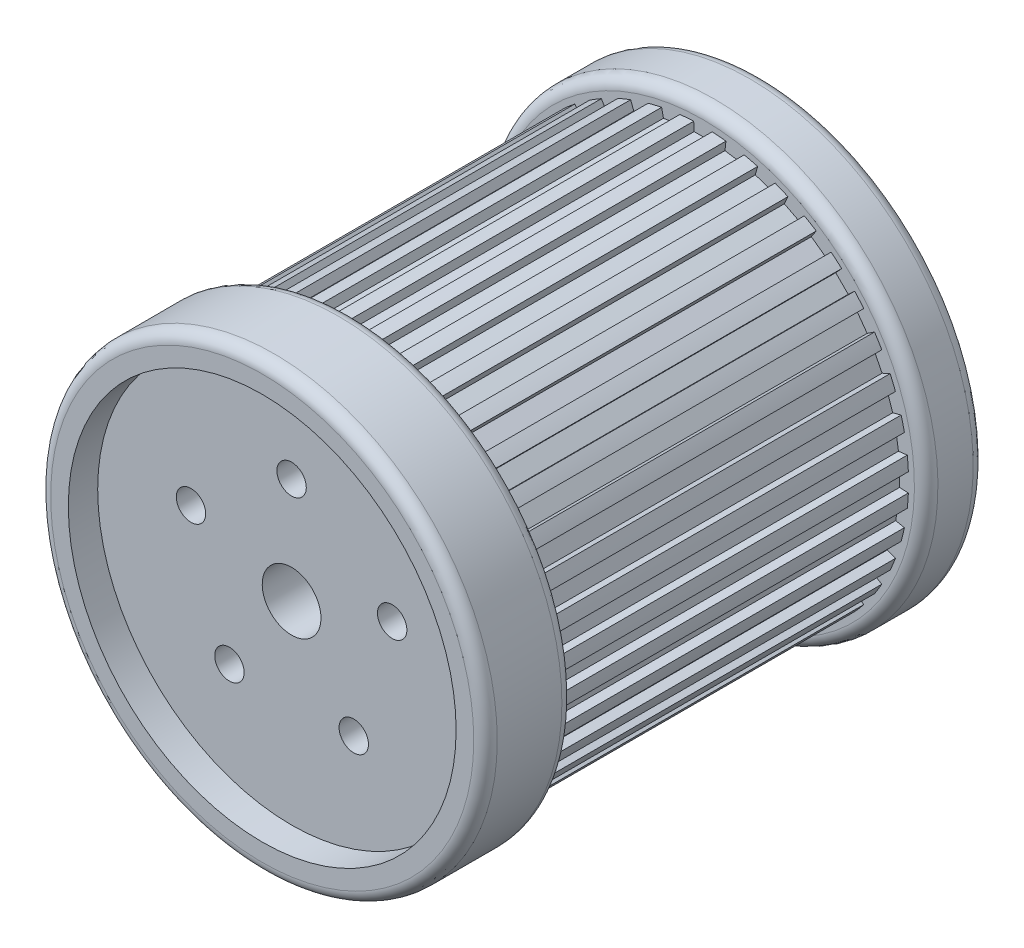
from build123d import *

# Parameters (mm, degrees)
SKETCH2_R           = 5
SKETCH2_R_2         = 2.5
CUT_EXTRUDE2_DEPTH  = 11
CUT_EXTRUDE3_DEPTH  = 70
SKETCH4_R           = 38
SKETCH4_R_2         = 35
BOSS_EXTRUDE1_DEPTH = 10
CIRPATTERN1_COUNT   = 40
SKETCH5_R           = 38
SKETCH5_R_2         = 33
BOSS_EXTRUDE2_DEPTH = 5
SKETCH6_R           = 38
SKETCH6_R_2         = 32
BOSS_EXTRUDE3_DEPTH = 10
FILLET1_R           = 3
FILLET2_R           = 2


with BuildPart() as part:
    # Sketch1 → Revolve1 (revolve)
    with BuildSketch(Plane(origin=(0, 0, 0), x_dir=(0, 0, -1), z_dir=(1, 0, 0))):
        Polygon((-17.5, 0), (-27.5, 0), (-27.5, -35), (52.5, -35), (52.5, -25), (-17.5, -25), align=None)
    revolve(axis=Axis((0, 0, 17.5), (0, 0, 1)))

    # Sketch2 → Cut-Extrude2 (cut, through all)
    with BuildSketch(Plane(origin=(0, 0, 17.5), x_dir=(-1, 0, 0), z_dir=(0, 0, -1))):
        Circle(SKETCH2_R)
        with Locations((0, 18)):
            Circle(SKETCH2_R_2)
        with Locations((17.119017293, 5.562305899)):
            Circle(SKETCH2_R_2)
        with Locations((10.580134541, -14.562305899)):
            Circle(SKETCH2_R_2)
        with Locations((-10.580134541, -14.562305899)):
            Circle(SKETCH2_R_2)
        with Locations((-17.119017293, 5.562305899)):
            Circle(SKETCH2_R_2)
    extrude(amount=-CUT_EXTRUDE2_DEPTH, mode=Mode.SUBTRACT)

    # Sketch3 → Cut-Extrude3 (cut)
    with BuildSketch(Plane(origin=(0, 0, -52.5), x_dir=(-1, 0, 0), z_dir=(0, 0, -1))):
        with BuildLine():
            Line((-1.5, 33.464893473), (1.5, 33.464893473))
            Line((1.5, 33.464893473), (1.567234638, 34.964893473))
            ThreePointArc((1.567234638, 34.964893473), (0, 35), (-1.567234638, 34.964893473))
            Line((-1.567234638, 34.964893473), (-1.5, 33.464893473))
        make_face()
    cut_extrude3 = extrude(amount=-CUT_EXTRUDE3_DEPTH, mode=Mode.SUBTRACT)

    # Sketch4 → Boss-Extrude1 (add)
    with BuildSketch(Plane.XY.offset(27.5)):
        Circle(SKETCH4_R)
        Circle(SKETCH4_R_2, mode=Mode.SUBTRACT)
    extrude(amount=-BOSS_EXTRUDE1_DEPTH)

    # CirPattern1: Cut-Extrude3 ×40 about axis
    cirpattern1_axis = Axis((0, 0, 0), (0, 0, 1))
    for i in range(1, CIRPATTERN1_COUNT):
        add(cut_extrude3.rotate(cirpattern1_axis, i * 360 / CIRPATTERN1_COUNT), mode=Mode.SUBTRACT)

    # Sketch5 → Boss-Extrude2 (add)
    with BuildSketch(Plane.XY.offset(27.5)):
        Circle(SKETCH5_R)
        Circle(SKETCH5_R_2, mode=Mode.SUBTRACT)
    extrude(amount=BOSS_EXTRUDE2_DEPTH)

    # Sketch6 → Boss-Extrude3 (add)
    with BuildSketch(Plane(origin=(0, 0, -52.5), x_dir=(-1, 0, 0), z_dir=(0, 0, -1))):
        Circle(SKETCH6_R)
        Circle(SKETCH6_R_2, mode=Mode.SUBTRACT)
    extrude(amount=-BOSS_EXTRUDE3_DEPTH)

    # Fillet1
    fillet1_edges = [part.edges().sort_by_distance(p)[0] for p in [
        (0, 25, -52.5),
    ]]
    fillet(fillet1_edges, radius=FILLET1_R)

    # Fillet2
    fillet2_edges = [part.edges().sort_by_distance(p)[0] for p in [
        (-38, 0, 17.5),
        (-38, 0, 32.5),
        (38, 0, -52.5),
        (38, 0, -42.5),
    ]]
    fillet(fillet2_edges, radius=FILLET2_R)


solid = part.part
